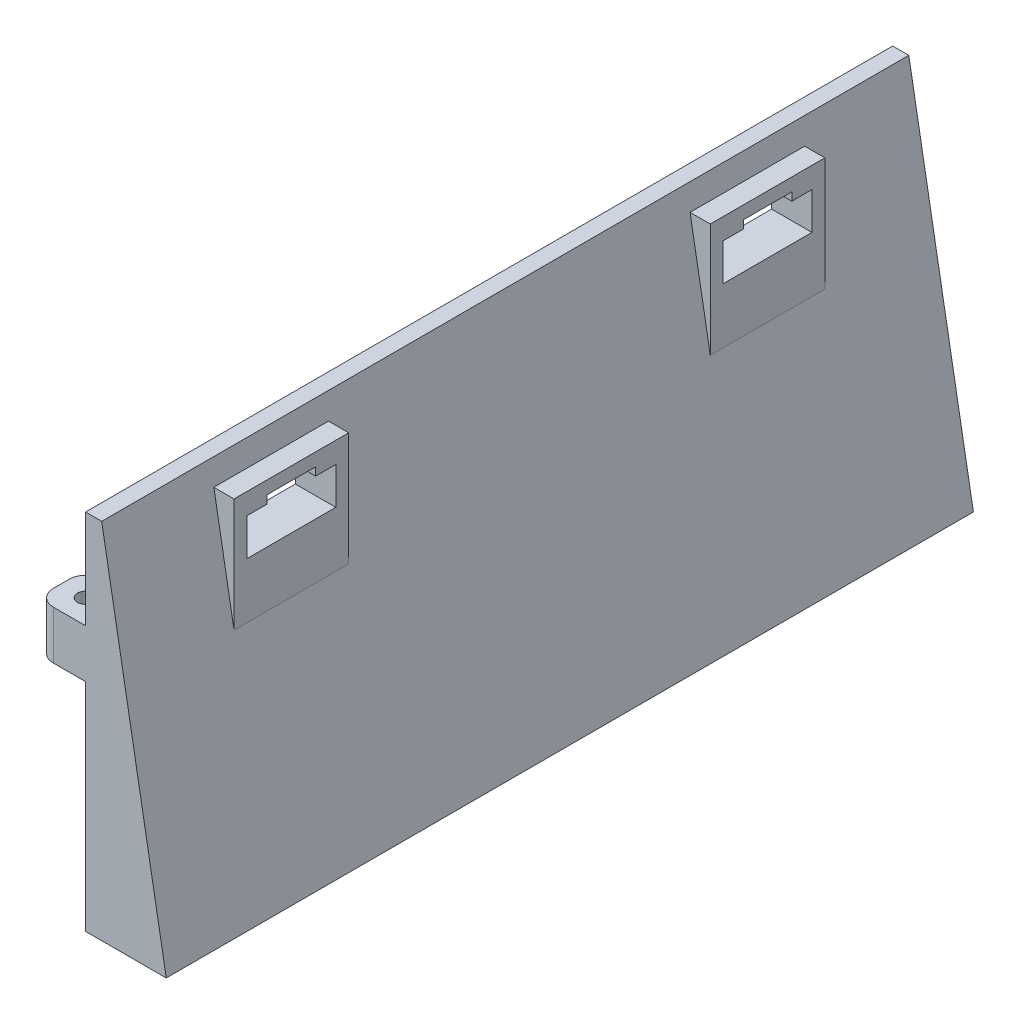
from build123d import *

# Parameters (mm, degrees)
BOSS_EXTRUDE1_DEPTH = 100
SKETCH3_W           = 6
SKETCH3_H           = 6
BOSS_EXTRUDE2_DEPTH = 6
SKETCH4_R           = 1
CUT_EXTRUDE2_DEPTH  = 10
SKETCH5_R           = 1
CUT_EXTRUDE3_DEPTH  = 10
FILLET1_R           = 1
FILLET2_R           = 2
SKETCH7_W           = 11
SKETCH7_H           = 5.6
CUT_EXTRUDE4_DEPTH  = 10
SKETCH13_W          = 6
SKETCH13_H          = 6
BOSS_EXTRUDE3_DEPTH = 6
SKETCH14_R          = 1
CUT_EXTRUDE7_DEPTH  = 6
SKETCH16_R          = 1
CUT_EXTRUDE8_DEPTH  = 6
FILLET3_R           = 2
FILLET4_R           = 1
BOSS_EXTRUDE4_DEPTH = 5
BOSS_EXTRUDE5_DEPTH = 5
SKETCH19_W          = 0.937777778
SKETCH19_H          = 14.2
BOSS_EXTRUDE6_DEPTH = 10
SKETCH20_W          = 0.937777778
SKETCH20_H          = 14.2
BOSS_EXTRUDE7_DEPTH = 10
SKETCH21_W          = 2
SKETCH21_H          = 2.5
BOSS_EXTRUDE8_DEPTH = 1
SKETCH22_W          = 2
SKETCH22_H          = 2.5
BOSS_EXTRUDE9_DEPTH = 1


with BuildPart() as part:
    # Sketch1 → Boss-Extrude1 (new body)
    with BuildSketch(Plane.XY):
        Polygon((0, 0), (10, 0), (2, 45), (0, 45), align=None)
    extrude(amount=BOSS_EXTRUDE1_DEPTH)

    # Sketch3 → Boss-Extrude2 (add)
    with BuildSketch(Plane.ZY):
        with Locations((15.5, 10.1)):
            Rectangle(SKETCH3_W, SKETCH3_H)
        with Locations((84.5, 10.1)):
            Rectangle(SKETCH3_W, SKETCH3_H)
    extrude(amount=BOSS_EXTRUDE2_DEPTH)

    # Sketch4 → Cut-Extrude2 (cut)
    with BuildSketch(Plane(origin=(0, 13.1, 0), x_dir=(1, 0, 0), z_dir=(0, 1, 0))):
        with Locations((-3, -84.5)):
            Circle(SKETCH4_R)
    extrude(amount=-CUT_EXTRUDE2_DEPTH, mode=Mode.SUBTRACT)

    # Sketch5 → Cut-Extrude3 (cut)
    with BuildSketch(Plane(origin=(0, 13.1, 0), x_dir=(1, 0, 0), z_dir=(0, 1, 0))):
        with Locations((-3, -15.5)):
            Circle(SKETCH5_R)
    extrude(amount=-CUT_EXTRUDE3_DEPTH, mode=Mode.SUBTRACT)

    # Fillet1
    fillet1_edges = [part.edges().sort_by_distance(p)[0] for p in [
        (0, 10.1, 12.5),
        (0, 10.1, 18.5),
        (0, 10.1, 87.5),
        (0, 10.1, 81.5),
    ]]
    fillet(fillet1_edges, radius=FILLET1_R)

    # Fillet2
    fillet2_edges = [part.edges().sort_by_distance(p)[0] for p in [
        (-6, 10.1, 12.5),
        (-6, 10.1, 18.5),
        (-6, 10.1, 87.5),
        (-6, 10.1, 81.5),
    ]]
    fillet(fillet2_edges, radius=FILLET2_R)

    # Sketch7 → Cut-Extrude4 (cut)
    with BuildSketch(Plane.ZY):
        with Locations((20.5, 37.8)):
            Rectangle(SKETCH7_W, SKETCH7_H)
        with Locations((79.5, 37.8)):
            Rectangle(SKETCH7_W, SKETCH7_H)
    extrude(amount=-CUT_EXTRUDE4_DEPTH, mode=Mode.SUBTRACT)

    # Sketch13 → Boss-Extrude3 (add)
    with BuildSketch(Plane.ZY):
        with Locations((3, 29.8)):
            Rectangle(SKETCH13_W, SKETCH13_H)
        with Locations((97, 29.8)):
            Rectangle(SKETCH13_W, SKETCH13_H)
    extrude(amount=BOSS_EXTRUDE3_DEPTH)

    # Sketch14 → Cut-Extrude7 (cut)
    with BuildSketch(Plane(origin=(0, 32.8, 0), x_dir=(1, 0, 0), z_dir=(0, 1, 0))):
        with Locations((-3, -3)):
            Circle(SKETCH14_R)
    extrude(amount=-CUT_EXTRUDE7_DEPTH, mode=Mode.SUBTRACT)

    # Sketch16 → Cut-Extrude8 (cut)
    with BuildSketch(Plane(origin=(0, 32.8, 0), x_dir=(1, 0, 0), z_dir=(0, 1, 0))):
        with Locations((-3, -97)):
            Circle(SKETCH16_R)
    extrude(amount=-CUT_EXTRUDE8_DEPTH, mode=Mode.SUBTRACT)

    # Fillet3
    fillet3_edges = [part.edges().sort_by_distance(p)[0] for p in [
        (-6, 29.8, 0),
        (-6, 29.8, 6),
        (-6, 29.8, 94),
        (-6, 29.8, 100),
    ]]
    fillet(fillet3_edges, radius=FILLET3_R)

    # Fillet4
    fillet4_edges = [part.edges().sort_by_distance(p)[0] for p in [
        (0, 29.8, 6),
        (0, 29.8, 94),
    ]]
    fillet(fillet4_edges, radius=FILLET4_R)

    # Sketch17 → Boss-Extrude4 (add)
    with BuildSketch(Plane.ZY):
        Polygon((15, 35), (13.4, 35), (13.4, 42.2), (15, 42.2), (27.6, 42.2), (27.6, 35), (26, 35), (26, 40.6), (15, 40.6), align=None)
        Polygon((74, 35), (72.4, 35), (72.4, 42.2), (74, 42.2), (86.6, 42.2), (86.6, 35), (85, 35), (85, 40.6), (74, 40.6), align=None)
    extrude(amount=-BOSS_EXTRUDE4_DEPTH)

    # Sketch18 → Boss-Extrude5 (add)
    with BuildSketch(Plane.ZY):
        Polygon((15, 35), (13.4, 35), (13.4, 33.4), (27.6, 33.4), (27.6, 35), (26, 35), align=None)
        Polygon((74, 35), (72.4, 35), (72.4, 33.4), (86.6, 33.4), (86.6, 35), (85, 35), align=None)
    extrude(amount=-BOSS_EXTRUDE5_DEPTH)

    # Sketch19 → Boss-Extrude6 (add)
    with BuildSketch(Plane.XZ.offset(-33.4)):
        with Locations((4.531111111, 79.5)):
            Rectangle(SKETCH19_W, SKETCH19_H)
    extrude(amount=BOSS_EXTRUDE6_DEPTH)

    # Sketch20 → Boss-Extrude7 (add)
    with BuildSketch(Plane.XZ.offset(-33.4)):
        with Locations((4.531111111, 20.5)):
            Rectangle(SKETCH20_W, SKETCH20_H)
    extrude(amount=BOSS_EXTRUDE7_DEPTH)

    # Sketch21 → Boss-Extrude8 (add)
    with BuildSketch(Plane.XZ.offset(-40.6)):
        with Locations((4, 83.75)):
            Rectangle(SKETCH21_W, SKETCH21_H)
        with Locations((4, 75.25)):
            Rectangle(SKETCH21_W, SKETCH21_H)
    extrude(amount=BOSS_EXTRUDE8_DEPTH)

    # Sketch22 → Boss-Extrude9 (add)
    with BuildSketch(Plane.XZ.offset(-40.6)):
        with Locations((4, 16.25)):
            Rectangle(SKETCH22_W, SKETCH22_H)
        with Locations((4, 24.75)):
            Rectangle(SKETCH22_W, SKETCH22_H)
    extrude(amount=BOSS_EXTRUDE9_DEPTH)


solid = part.part
